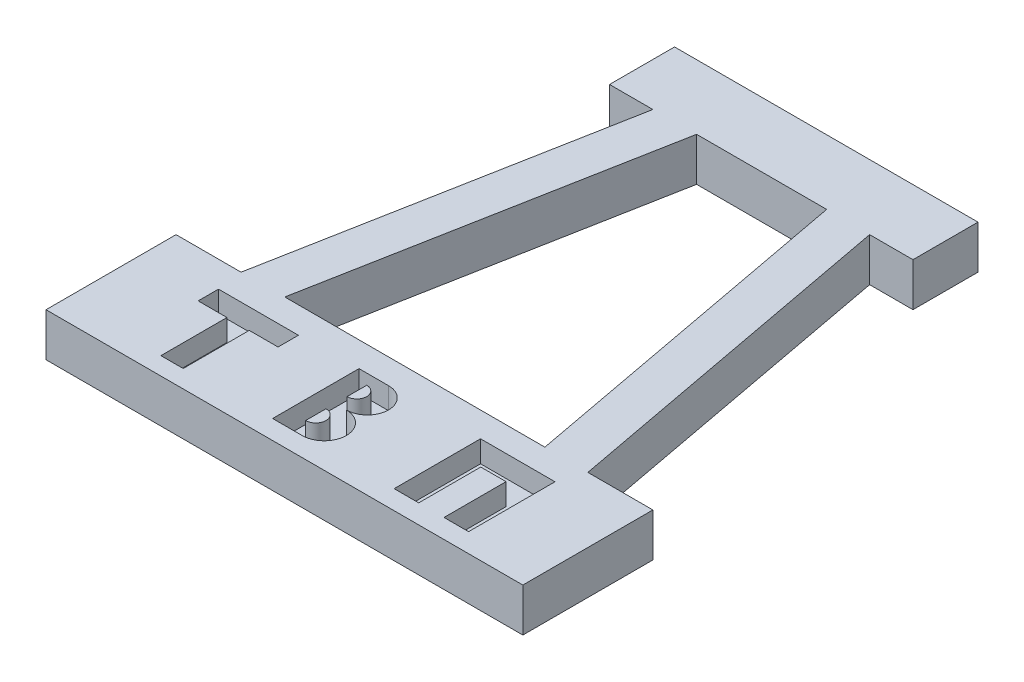
from build123d import *

# Parameters (mm, degrees)
BOSS_EXTRUDE1_DEPTH     = 12.7
CUT_EXTRUDE2_DEPTH      = 33.274
CUT_EXTRUDE2_DEPTH_BACK = 25.4
CUT_EXTRUDE3_DEPTH      = 6.35
CUT_EXTRUDE4_DEPTH      = 6.35
CUT_EXTRUDE5_DEPTH      = 6.35


with BuildPart() as part:
    # Sketch1 → Boss-Extrude1 (new body)
    with BuildSketch(Plane(origin=(0, 0, 0), x_dir=(1, 0, 0), z_dir=(0, 1, 0))):
        Polygon((-69.85, 0), (0, 0), (69.85, 0), (69.85, 38.1), (50.8, 38.1), (31.75, 139.7), (44.45, 139.7), (44.45, 158.75), (0, 158.75), (-44.45, 158.75), (-44.45, 139.7), (-31.75, 139.7), (-50.8, 38.1), (-69.85, 38.1), align=None)
    extrude(amount=BOSS_EXTRUDE1_DEPTH)

    # Sketch3 → Cut-Extrude2 (cut, two sides)
    with BuildSketch(Plane(origin=(0, 0, 0), x_dir=(1, 0, 0), z_dir=(0, 1, 0))) as cut_extrude2_sk:
        Polygon((0, 38.209887603), (-38.1, 38.209887603), (-19.05, 139.809887603), (0, 139.809887603), (19.05, 139.809887603), (38.1, 38.209887603), align=None)
    extrude(amount=CUT_EXTRUDE2_DEPTH, mode=Mode.SUBTRACT)
    extrude(cut_extrude2_sk.sketch, amount=-CUT_EXTRUDE2_DEPTH_BACK, mode=Mode.SUBTRACT)

    # Sketch4 → Cut-Extrude3 (cut)
    with BuildSketch(Plane(origin=(0, 12.7, 0), x_dir=(1, 0, 0), z_dir=(0, 1, 0))):
        Polygon((-38.1, 30.497184411), (-26.396078431, 30.497184411), (-26.396078431, 24.528945876), (-34.833932912, 24.528945876), (-34.833932912, 5.183620969), (-38.1, 5.183620969), (-41.366067088, 5.183620969), (-41.366067088, 24.528945876), (-49.803921569, 24.528945876), (-49.803921569, 30.497184411), align=None)
    extrude(amount=-CUT_EXTRUDE3_DEPTH, mode=Mode.SUBTRACT)

    # Sketch5 → Cut-Extrude4 (cut)
    with BuildSketch(Plane(origin=(0, 12.7, 0), x_dir=(1, 0, 0), z_dir=(0, 1, 0))):
        with BuildLine():
            Line((-9.055258467, 5.595223627), (-9.055258467, 30.908787069))
            Line((-9.055258467, 30.908787069), (-0.411602658, 30.908787069))
            ThreePointArc((-0.411602658, 30.908787069), (5.762437206, 24.734747205), (-0.411602658, 18.560707341))
            ThreePointArc((-0.411602658, 18.560707341), (6.071139199, 12.077965484), (-0.411602658, 5.595223627))
            Line((-0.411602658, 5.595223627), (-9.055258467, 5.595223627))
        make_face()
        with BuildLine():
            Line((-3.704423918, 9.917051531), (-3.704423918, 15.885290066))
            ThreePointArc((-3.704423918, 15.885290066), (-0.720304651, 12.901170799), (-3.704423918, 9.917051531))
        make_face(mode=Mode.SUBTRACT)
        with BuildLine():
            Line((-3.704423918, 22.05932993), (-3.704423918, 27.821767137))
            ThreePointArc((-3.704423918, 27.821767137), (-0.823205315, 24.940548533), (-3.704423918, 22.05932993))
        make_face(mode=Mode.SUBTRACT)
    extrude(amount=-CUT_EXTRUDE4_DEPTH, mode=Mode.SUBTRACT)

    # Sketch6 → Cut-Extrude5 (cut)
    with BuildSketch(Plane(origin=(0, 12.7, 0), x_dir=(1, 0, 0), z_dir=(0, 1, 0))):
        Polygon((26.548371415, 5.595223627), (33.751417923, 5.595223627), (33.751417923, 23.769556722), (41.160265759, 23.769556722), (41.160265759, 5.595223627), (48.363312267, 5.595223627), (48.363312267, 30.908787069), (26.548371415, 30.908787069), align=None)
    extrude(amount=-CUT_EXTRUDE5_DEPTH, mode=Mode.SUBTRACT)


solid = part.part
